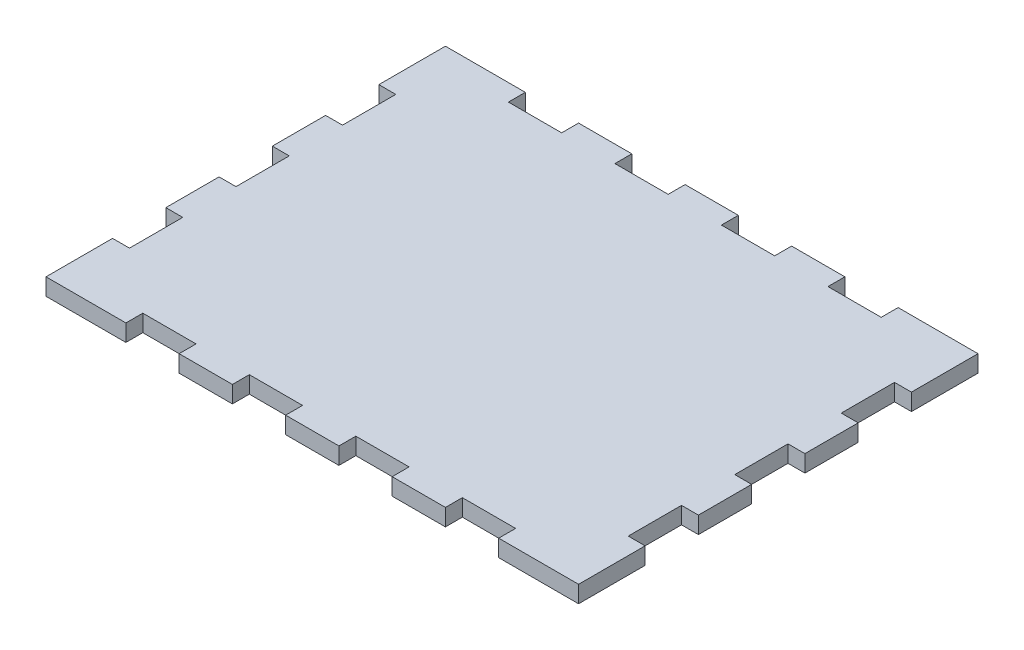
from build123d import *

# Parameters (mm, degrees)
BOSS_EXTRUDE1_DEPTH = 6.35


with BuildPart() as part:
    # Sketch1 → Boss-Extrude1 (new body)
    with BuildSketch(Plane(origin=(0, 0, 0), x_dir=(1, 0, 0), z_dir=(0, 1, 0))):
        Polygon((90, 0), (110, 0), (110, 6.35), (130, 6.35), (130, 0), (150, 0), (150, 6.35), (170, 6.35), (170, 0), (200, 0), (200, 25), (193.65, 25), (193.65, 45), (200, 45), (200, 65), (193.65, 65), (193.65, 85), (200, 85), (200, 105), (193.65, 105), (193.65, 125), (200, 125), (200, 150), (170, 150), (170, 143.65), (150, 143.65), (150, 150), (130, 150), (130, 143.65), (110, 143.65), (110, 150), (90, 150), (90, 143.65), (70, 143.65), (70, 150), (50, 150), (50, 143.65), (30, 143.65), (30, 150), (0, 150), (0, 125), (6.35, 125), (6.35, 105), (0, 105), (0, 85), (6.35, 85), (6.35, 65), (0, 65), (0, 45), (6.35, 45), (6.35, 25), (0, 25), (0, 0), (30, 0), (30, 6.35), (50, 6.35), (50, 0), (70, 0), (70, 6.35), (90, 6.35), align=None)
    extrude(amount=BOSS_EXTRUDE1_DEPTH)


solid = part.part
